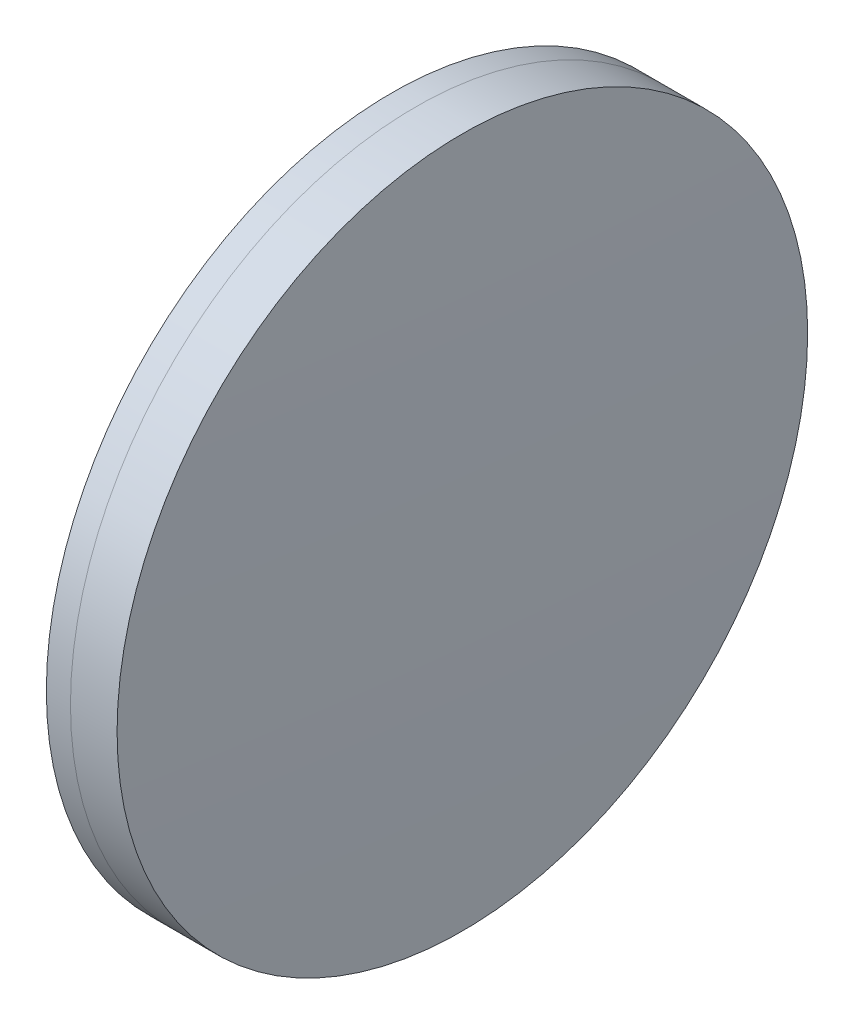
from build123d import *


with BuildPart() as part:
    # 草图1 one side → 旋转1 (revolve)
    with BuildSketch(Plane(origin=(0, 0, 0), x_dir=(1, 0, 0), z_dir=(0, 1, 0)), mode=Mode.PRIVATE) as revolve_1_sk:
        with BuildLine():
            ThreePointArc((291.915018212, 25), (291.309917427, 12.506508714), (291.108147161, 0))
            Line((291.108147161, 0), (294.888147161, 0))
            ThreePointArc((294.888147161, 0), (294.581252894, 12.515042297), (293.661307828, 25))
            Line((293.661307828, 25), (291.915018212, 25))
        make_face()
    revolve(revolve_1_sk.sketch.rotate(Axis((124.523309526, 0, 0), (1, 0, 0)), 180), axis=Axis((124.523309526, 0, 0), (1, 0, 0)))  # turned: the seam where the file's is


with BuildPart() as body_2:
    # 草图2 one side → 旋转3 (revolve)
    with BuildSketch(Plane(origin=(0, 0, 0), x_dir=(1, 0, 0), z_dir=(0, 1, 0)), mode=Mode.PRIVATE) as revolve_3_sk:
        with BuildLine():
            Line((297.036349573, 25), (293.661307828, 25))
            ThreePointArc((293.661307828, 25), (294.581252894, 12.515042297), (294.888147161, 0))
            Line((294.888147161, 0), (297.408147161, 0))
            ThreePointArc((297.408147161, 0), (297.315192625, 12.501382258), (297.036349573, 25))
        make_face()
    revolve(revolve_3_sk.sketch.rotate(Axis((-0.551919993, 0, 0), (1, 0, 0)), 180), axis=Axis((-0.551919993, 0, 0), (1, 0, 0)))  # turned: the seam where the file's is


solid = Compound([part.part, body_2.part])
